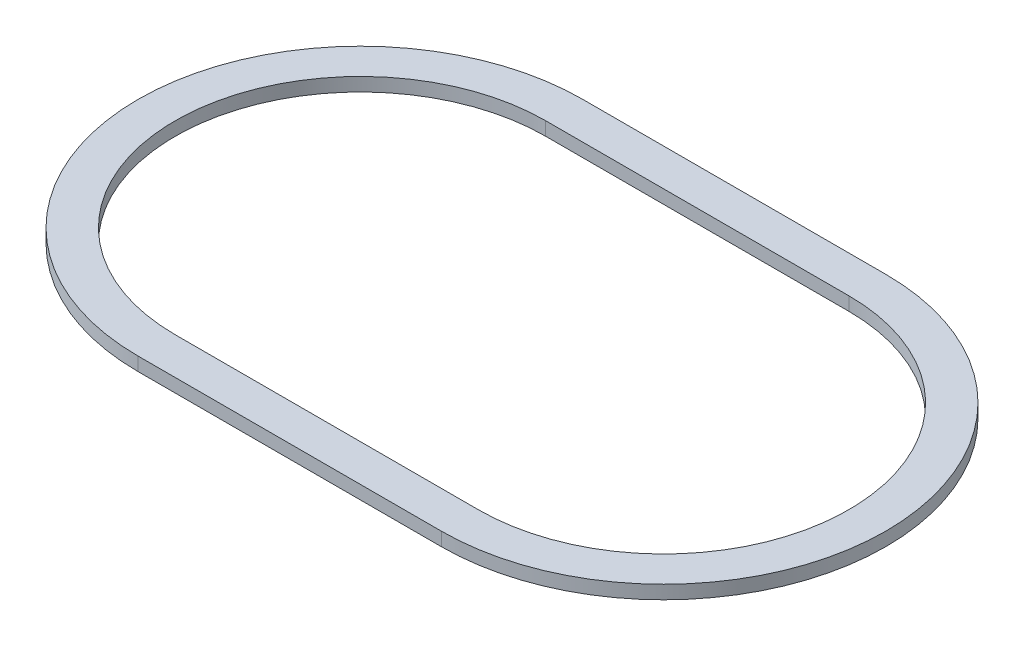
from build123d import *

# Parameters (mm, degrees)
EXTRUDE_1_DEPTH     = 2
CUT_EXTRUDE_1_DEPTH = 3


with BuildPart() as part:
    # Эскиз1 → Бобышка-Вытянуть1 (new body)
    with BuildSketch(Plane(origin=(0, 0, 0), x_dir=(1, 0, 0), z_dir=(0, 1, 0))):
        with BuildLine():
            Line((-22.5, 33), (22.5, 33))
            ThreePointArc((22.5, 33), (55.5, 0), (22.5, -33))
            Line((22.5, -33), (-22.5, -33))
            ThreePointArc((-22.5, -33), (-55.5, 0), (-22.5, 33))
        make_face()
    extrude(amount=EXTRUDE_1_DEPTH)

    # Эскиз2 → Вырез-Вытянуть1 (cut, through all)
    with BuildSketch(Plane(origin=(0, 2, 0), x_dir=(1, 0, 0), z_dir=(0, 1, 0))):
        with BuildLine():
            Line((-22.5, 27.5), (22.5, 27.5))
            ThreePointArc((22.5, 27.5), (50, 0), (22.5, -27.5))
            Line((22.5, -27.5), (-22.5, -27.5))
            ThreePointArc((-22.5, -27.5), (-50, 0), (-22.5, 27.5))
        make_face()
    extrude(amount=-CUT_EXTRUDE_1_DEPTH, mode=Mode.SUBTRACT)


solid = part.part
